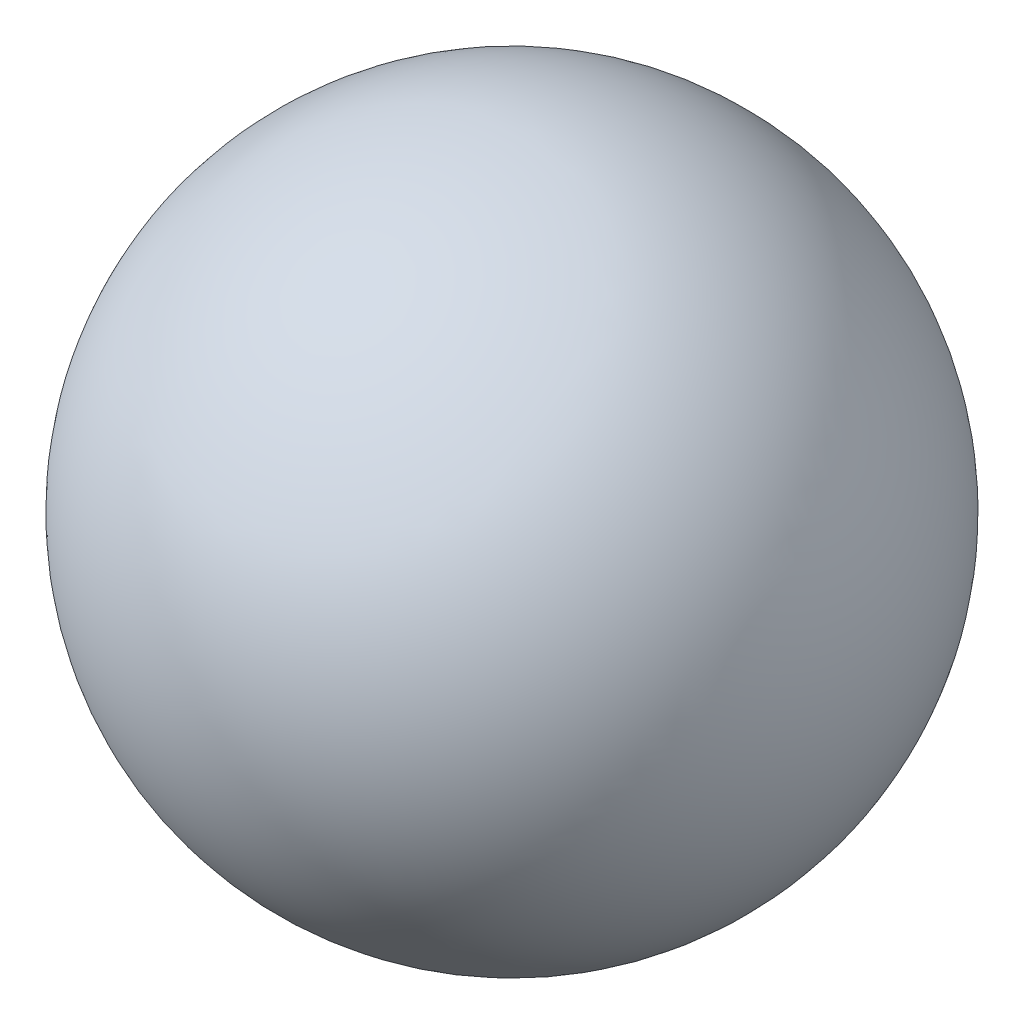
from build123d import *


with BuildPart() as part:
    # 草图1 → 旋转3 (revolve)
    with BuildSketch(Plane.XY):
        with BuildLine():
            Line((-5, 0), (-3, 0))
            ThreePointArc((-3, 0), (0, 3), (3, 0))
            Line((3, 0), (5, 0))
            ThreePointArc((5, 0), (0, 5), (-5, 0))
        make_face()
    revolve(axis=Axis((-5, 0, 0), (1, 0, 0)))


solid = part.part
